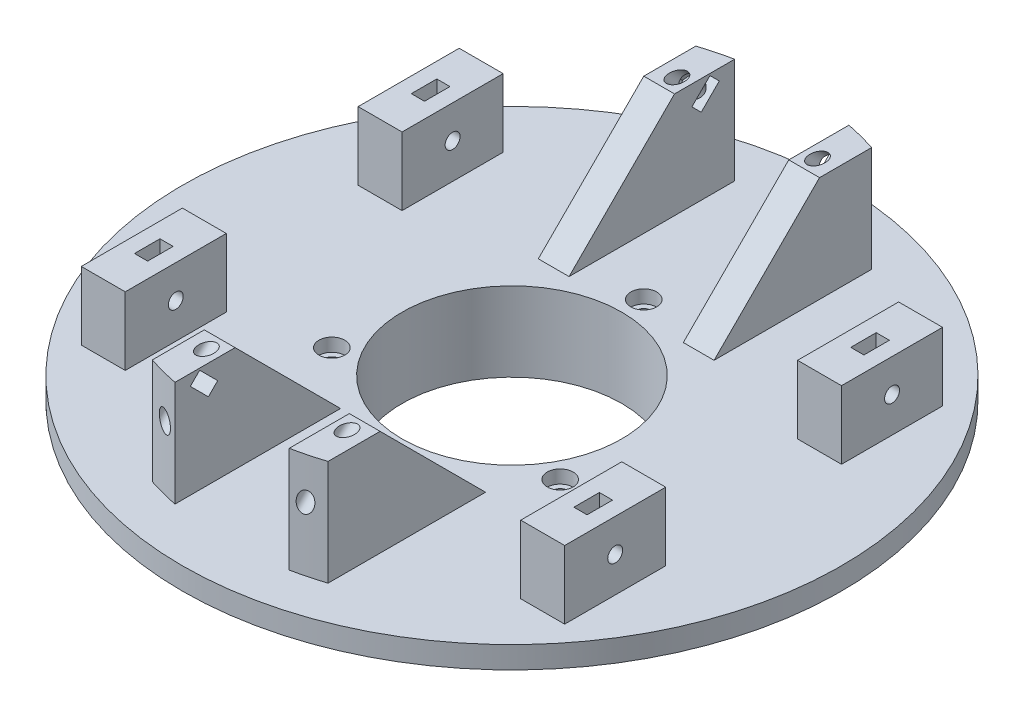
from build123d import *

# Parameters (mm, degrees)
CROQUIS2_W                = 10
CROQUIS2_H                = 23
SALIENTE_EXTRUIR1_DEPTH   = 15.5
CROQUIS3_R                = 1.7
CORTAR_EXTRUIR1_DEPTH     = 15
CORTAR_EXTRUIR2_DEPTH     = 1.5
SIMETR_A2_COPY_1_SKETCH_W = 10
SIMETR_A2_COPY_1_SKETCH_H = 23
SIMETR_A2_COPY_1_DEPTH    = 15.5
SIMETR_A2_COPY_2_SKETCH_R = 1.7
SIMETR_A2_COPY_2_DEPTH    = 15
SIMETR_A2_COPY_3_DEPTH    = 1.5
CROQUIS5_R                = 1.7
CORTAR_EXTRUIR3_DEPTH     = 40.5
CROQUIS6_R                = 2.95
CORTAR_EXTRUIR4_DEPTH     = 3
MATRIZC1_COUNT            = 3
SALIENTE_EXTRUIR2_DEPTH   = 24
CORTAR_EXTRUIR5_DEPTH     = 10
CROQUIS9_R                = 1.7
CORTAR_EXTRUIR6_DEPTH     = 20
CORTAR_EXTRUIR7_DEPTH     = 3
SIMETR_A4_COPY_1_DEPTH    = 24
SIMETR_A4_COPY_2_DEPTH    = 10
SIMETR_A4_COPY_3_SKETCH_R = 1.7
SIMETR_A4_COPY_3_DEPTH    = 20
SIMETR_A4_COPY_4_DEPTH    = 3


with BuildPart() as part:
    # Croquis1 → Revolución1 (revolve)
    with BuildSketch(Plane.XY):
        Polygon((25, 0), (25, 18), (75, 18), (75, 13), (47, 13), (47, 6), (35, 6), (35, 0), align=None)
    revolve(axis=Axis((0, 49.685096011, 0), (0, -1, 0)))

    # Croquis2 → Saliente-Extruir1 (add)
    with BuildSketch(Plane(origin=(0, 18, 0), x_dir=(1, 0, 0), z_dir=(0, 1, 0))):
        with Locations((-50, -31.5)):
            Rectangle(CROQUIS2_W, CROQUIS2_H)
    saliente_extruir1 = extrude(amount=SALIENTE_EXTRUIR1_DEPTH)

    # Croquis3 → Cortar-Extruir1 (cut)
    with BuildSketch(Plane.ZY.offset(55)):
        with Locations((31.5, 26)):
            Circle(CROQUIS3_R)
    cortar_extruir1 = extrude(amount=-CORTAR_EXTRUIR1_DEPTH, mode=Mode.SUBTRACT)

    # Croquis4 → Cortar-Extruir2 (cut, symmetric)
    with BuildSketch(Plane.ZY.offset(50)):
        Polygon((28.598814897, 27.175), (28.598814897, 37.175), (34.401185103, 37.175), (34.401185103, 27.175), (34.401185103, 24.325), (31.5, 22.65), (28.598814897, 24.325), align=None)
    cortar_extruir2 = extrude(amount=CORTAR_EXTRUIR2_DEPTH, both=True, mode=Mode.SUBTRACT)

    # Simetría1: Saliente-Extruir1, Cortar-Extruir1, Cortar-Extruir2 across plane
    add(saliente_extruir1.mirror(Plane(origin=(0, 0, 0), x_dir=(0, 0, 1), z_dir=(1, 0, 0))))
    add(cortar_extruir1.mirror(Plane(origin=(0, 0, 0), x_dir=(0, 0, 1), z_dir=(1, 0, 0))), mode=Mode.SUBTRACT)
    add(cortar_extruir2.mirror(Plane(origin=(0, 0, 0), x_dir=(0, 0, 1), z_dir=(1, 0, 0))), mode=Mode.SUBTRACT)

    # Simetría2: Saliente-Extruir1, Cortar-Extruir1, Cortar-Extruir2 across plane
    add(saliente_extruir1.mirror(Plane.XY))
    add(cortar_extruir1.mirror(Plane.XY), mode=Mode.SUBTRACT)
    add(cortar_extruir2.mirror(Plane.XY), mode=Mode.SUBTRACT)

    # Simetría2 copy 1 sketch → Simetría2 copy 1 (add)
    with BuildSketch(Plane(origin=(0, 18, 0), x_dir=(-1, 0, 0), z_dir=(0, 1, 0))):
        with Locations((-50, -31.5)):
            Rectangle(SIMETR_A2_COPY_1_SKETCH_W, SIMETR_A2_COPY_1_SKETCH_H)
    extrude(amount=SIMETR_A2_COPY_1_DEPTH)

    # Simetría2 copy 2 sketch → Simetría2 copy 2 (cut)
    with BuildSketch(Plane(origin=(55, 0, 0), x_dir=(0, 0, -1), z_dir=(1, 0, 0))):
        with Locations((31.5, 26)):
            Circle(SIMETR_A2_COPY_2_SKETCH_R)
    extrude(amount=-SIMETR_A2_COPY_2_DEPTH, mode=Mode.SUBTRACT)

    # Simetría2 copy 3 sketch → Simetría2 copy 3 (cut, symmetric)
    with BuildSketch(Plane(origin=(50, 0, 0), x_dir=(0, 0, -1), z_dir=(1, 0, 0))):
        Polygon((28.598814897, 27.175), (28.598814897, 37.175), (34.401185103, 37.175), (34.401185103, 27.175), (34.401185103, 24.325), (31.5, 22.65), (28.598814897, 24.325), align=None)
    extrude(amount=SIMETR_A2_COPY_3_DEPTH, both=True, mode=Mode.SUBTRACT)

    # Croquis5 → Cortar-Extruir3 (cut)
    with BuildSketch(Plane(origin=(0, 18, 0), x_dir=(1, 0, 0), z_dir=(0, 1, 0))):
        with Locations((0, 30)):
            Circle(CROQUIS5_R)
    cortar_extruir3 = extrude(amount=-CORTAR_EXTRUIR3_DEPTH, mode=Mode.SUBTRACT)

    # Croquis6 → Cortar-Extruir4 (cut)
    with BuildSketch(Plane(origin=(0, 18, 0), x_dir=(1, 0, 0), z_dir=(0, 1, 0))):
        with Locations((0, 30)):
            Circle(CROQUIS6_R)
    cortar_extruir4 = extrude(amount=-CORTAR_EXTRUIR4_DEPTH, mode=Mode.SUBTRACT)

    # MatrizC1: Cortar-Extruir3, Cortar-Extruir4 ×3 about axis
    matrizc1_axis = Axis((0, 0, 0), (0, 1, 0))
    for i in range(1, MATRIZC1_COUNT):
        add(cortar_extruir3.rotate(matrizc1_axis, i * 360 / MATRIZC1_COUNT), mode=Mode.SUBTRACT)
        add(cortar_extruir4.rotate(matrizc1_axis, i * 360 / MATRIZC1_COUNT), mode=Mode.SUBTRACT)

    # Croquis7 → Saliente-Extruir2 (add)
    with BuildSketch(Plane(origin=(0, 18, 0), x_dir=(1, 0, 0), z_dir=(0, 1, 0))):
        with BuildLine():
            Line((13, 63.686733312), (13, 26))
            Line((13, 26), (20, 26))
            Line((20, 26), (20, 61.846584384))
            ThreePointArc((20, 61.846584384), (16.525632727, 62.864166764), (13, 63.686733312))
        make_face()
    saliente_extruir2 = extrude(amount=SALIENTE_EXTRUIR2_DEPTH)

    # Croquis8 → Cortar-Extruir5 (cut)
    with BuildSketch(Plane.ZY.offset(-13)):
        Polygon((-26, 18), (-71, 63), (-26, 63), align=None)
    cortar_extruir5 = extrude(amount=-CORTAR_EXTRUIR5_DEPTH, mode=Mode.SUBTRACT)

    # Croquis9 → Cortar-Extruir6 (cut)
    with BuildSketch(Plane(origin=(0, -4, -4), x_dir=(1, 0, 0), z_dir=(0, 0.707106781, 0.707106781))):
        with Locations((16, 67.553823869)):
            Circle(CROQUIS9_R)
    cortar_extruir6 = extrude(amount=-CORTAR_EXTRUIR6_DEPTH, mode=Mode.SUBTRACT)

    # Croquis10 → Cortar-Extruir7 (cut)
    with BuildSketch(Plane(origin=(0, -10.363961031, -10.363961031), x_dir=(1, 0, 0), z_dir=(0, 0.707106781, 0.707106781))):
        Polygon((17.675, 64.652638766), (19.35, 67.553823869), (17.675, 70.455008972), (14.325, 70.455008972), (7.675, 70.455008972), (7.675, 64.652638766), (14.325, 64.652638766), align=None)
    cortar_extruir7 = extrude(amount=CORTAR_EXTRUIR7_DEPTH, mode=Mode.SUBTRACT)

    # Simetría3: Saliente-Extruir2, Cortar-Extruir5, Cortar-Extruir6, Cortar-Extruir7 across plane
    add(saliente_extruir2.mirror(Plane(origin=(0, 0, 0), x_dir=(0, 0, 1), z_dir=(1, 0, 0))))
    add(cortar_extruir5.mirror(Plane(origin=(0, 0, 0), x_dir=(0, 0, 1), z_dir=(1, 0, 0))), mode=Mode.SUBTRACT)
    add(cortar_extruir6.mirror(Plane(origin=(0, 0, 0), x_dir=(0, 0, 1), z_dir=(1, 0, 0))), mode=Mode.SUBTRACT)
    add(cortar_extruir7.mirror(Plane(origin=(0, 0, 0), x_dir=(0, 0, 1), z_dir=(1, 0, 0))), mode=Mode.SUBTRACT)

    # Simetría4: Saliente-Extruir2, Cortar-Extruir5, Cortar-Extruir6, Cortar-Extruir7 across plane
    add(saliente_extruir2.mirror(Plane.XY))
    add(cortar_extruir5.mirror(Plane.XY), mode=Mode.SUBTRACT)
    add(cortar_extruir6.mirror(Plane.XY), mode=Mode.SUBTRACT)
    add(cortar_extruir7.mirror(Plane.XY), mode=Mode.SUBTRACT)

    # Simetría4 copy 1 sketch → Simetría4 copy 1 (add)
    with BuildSketch(Plane(origin=(0, 18, 0), x_dir=(-1, 0, 0), z_dir=(0, 1, 0))):
        with BuildLine():
            Line((13, 63.686733312), (13, 26))
            Line((13, 26), (20, 26))
            Line((20, 26), (20, 61.846584384))
            ThreePointArc((20, 61.846584384), (16.525632727, 62.864166764), (13, 63.686733312))
        make_face()
    extrude(amount=SIMETR_A4_COPY_1_DEPTH)

    # Simetría4 copy 2 sketch → Simetría4 copy 2 (cut)
    with BuildSketch(Plane(origin=(-13, 0, 0), x_dir=(0, 0, -1), z_dir=(1, 0, 0))):
        Polygon((-26, 18), (-71, 63), (-26, 63), align=None)
    extrude(amount=-SIMETR_A4_COPY_2_DEPTH, mode=Mode.SUBTRACT)

    # Simetría4 copy 3 sketch → Simetría4 copy 3 (cut)
    with BuildSketch(Plane(origin=(0, -4, 4), x_dir=(-1, 0, 0), z_dir=(0, 0.707106781, -0.707106781))):
        with Locations((16, 67.553823869)):
            Circle(SIMETR_A4_COPY_3_SKETCH_R)
    extrude(amount=-SIMETR_A4_COPY_3_DEPTH, mode=Mode.SUBTRACT)

    # Simetría4 copy 4 sketch → Simetría4 copy 4 (cut)
    with BuildSketch(Plane(origin=(0, -10.363961031, 10.363961031), x_dir=(-1, 0, 0), z_dir=(0, 0.707106781, -0.707106781))):
        Polygon((17.675, 64.652638766), (19.35, 67.553823869), (17.675, 70.455008972), (14.325, 70.455008972), (7.675, 70.455008972), (7.675, 64.652638766), (14.325, 64.652638766), align=None)
    extrude(amount=SIMETR_A4_COPY_4_DEPTH, mode=Mode.SUBTRACT)


solid = part.part
